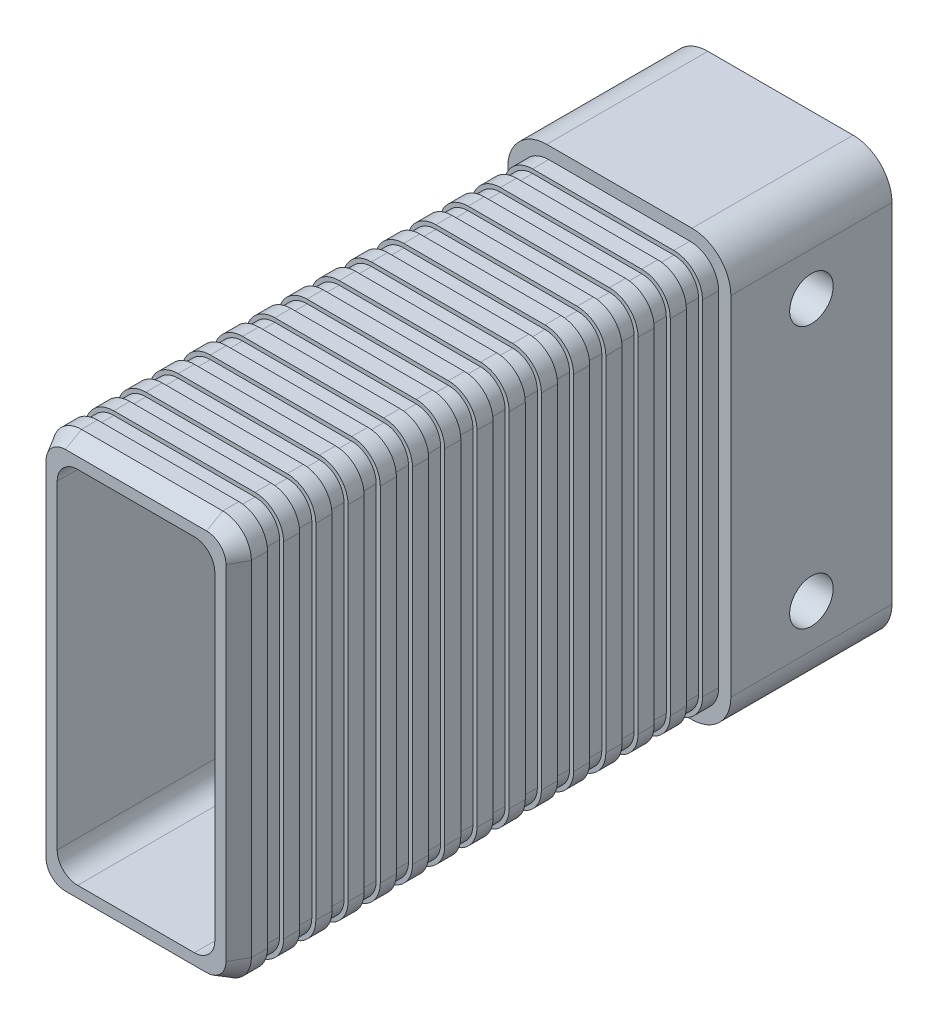
from build123d import *
from OCP.BRepFilletAPI import BRepFilletAPI_MakeChamfer

# Parameters (mm, degrees)
SKETCH1_W             = 24.646
SKETCH1_H             = 49.792
BOSS_EXTRUDE1_DEPTH   = 60
SKETCH2_W             = 27.686
SKETCH2_H             = 52.832
BOSS_EXTRUDE2_DEPTH   = 20
FILLET1_R             = 3.556
FILLET2_R             = 4.826
F_5_0MM_DOWEL_HOLE2_D = 5.4
CUT_EXTRUDE1_DEPTH    = 86.378180497
CUT_EXTRUDE2_START    = -4
CUT_EXTRUDE2_DEPTH    = 2
LPATTERN1_COUNT       = 14
LPATTERN1_PITCH       = 4
CHAMFER1_SIZE         = 2
CHAMFER1_SIZE2        = 1.154700538


with BuildPart() as part:
    # Sketch1 → Boss-Extrude1 (new body)
    with BuildSketch(Plane.XY):
        Rectangle(SKETCH1_W, SKETCH1_H)
    extrude(amount=BOSS_EXTRUDE1_DEPTH)

    # Sketch2 → Boss-Extrude2 (add)
    with BuildSketch(Plane.XY):
        Rectangle(SKETCH2_W, SKETCH2_H)
    extrude(amount=-BOSS_EXTRUDE2_DEPTH)

    # Fillet1
    fillet1_edges = [part.edges().sort_by_distance(p)[0] for p in [
        (-12.323, 24.896, 30),
        (12.323, 24.896, 30),
        (12.323, -24.896, 30),
        (-12.323, -24.896, 30),
    ]]
    fillet(fillet1_edges, radius=FILLET1_R)

    # Fillet2
    fillet2_edges = [part.edges().sort_by_distance(p)[0] for p in [
        (-13.843, -26.416, -10),
        (-13.843, 26.416, -10),
        (13.843, 26.416, -10),
        (13.843, -26.416, -10),
    ]]
    fillet(fillet2_edges, radius=FILLET2_R)

    # Ø5.0mm Dowel Hole2 (through all)
    with Locations(Plane(origin=(13.843, 0, 0), x_dir=(0, 0, -1), z_dir=(1, 0, 0))):
        with Locations((10, 16.256), (10, -16.256)):
            Hole(F_5_0MM_DOWEL_HOLE2_D / 2)

    # Sketch9 → Cut-Extrude1 (cut, through all)
    with BuildSketch(Plane.XY.offset(60)):
        with BuildLine():
            Line((7.243, -22.356), (-7.243, -22.356))
            ThreePointArc((-7.243, -22.356), (-9.039051224, -21.612051224), (-9.783, -19.816))
            Line((-9.783, -19.816), (-9.783, 19.816))
            ThreePointArc((-9.783, 19.816), (-9.039051224, 21.612051224), (-7.243, 22.356))
            Line((-7.243, 22.356), (7.243, 22.356))
            ThreePointArc((7.243, 22.356), (9.039051224, 21.612051224), (9.783, 19.816))
            Line((9.783, 19.816), (9.783, -19.816))
            ThreePointArc((9.783, -19.816), (9.039051224, -21.612051224), (7.243, -22.356))
        make_face()
    extrude(amount=-CUT_EXTRUDE1_DEPTH, mode=Mode.SUBTRACT)

    # Sketch10 → Cut-Extrude2 (cut)
    with BuildSketch(Plane.XY.offset(60).offset(CUT_EXTRUDE2_START)):
        with BuildLine():
            Line((-12.323, 21.34), (-12.323, -21.34))
            ThreePointArc((-12.323, -21.34), (-11.281471714, -23.854471714), (-8.767, -24.896))
            Line((-8.767, -24.896), (8.767, -24.896))
            ThreePointArc((8.767, -24.896), (11.281471714, -23.854471714), (12.323, -21.34))
            Line((12.323, -21.34), (12.323, 21.34))
            ThreePointArc((12.323, 21.34), (11.281471714, 23.854471714), (8.767, 24.896))
            Line((8.767, 24.896), (-8.767, 24.896))
            ThreePointArc((-8.767, 24.896), (-11.281471714, 23.854471714), (-12.323, 21.34))
        make_face()
        with BuildLine():
            Line((-11.823, 21.34), (-11.823, -21.34))
            ThreePointArc((-11.823, -21.34), (-10.927918323, -23.500918323), (-8.767, -24.396))
            Line((-8.767, -24.396), (8.767, -24.396))
            ThreePointArc((8.767, -24.396), (10.927918323, -23.500918323), (11.823, -21.34))
            Line((11.823, -21.34), (11.823, 21.34))
            ThreePointArc((11.823, 21.34), (10.927918323, 23.500918323), (8.767, 24.396))
            Line((8.767, 24.396), (-8.767, 24.396))
            ThreePointArc((-8.767, 24.396), (-10.927918323, 23.500918323), (-11.823, 21.34))
        make_face(mode=Mode.SUBTRACT)
    cut_extrude2 = extrude(amount=-CUT_EXTRUDE2_DEPTH, mode=Mode.SUBTRACT)

    # LPattern1: Cut-Extrude2 ×14
    with Locations(*[(0, 0, -i * LPATTERN1_PITCH) for i in range(1, LPATTERN1_COUNT)]):
        add(cut_extrude2, mode=Mode.SUBTRACT)

    # Chamfer1: one chamfer whose edges measure the first distance from different faces: ONE call of the kernel's chamfer builder (chamfer() names one face for all edges)
    chamfer1_edges_1 = [part.edges().sort_by_distance(p)[0] for p in [
        (0, -24.896, 60),
    ]]
    chamfer1_side_1 = [part.faces().sort_by_distance(p)[0] for p in [
        (0, -24.896, 58),
    ]]
    chamfer1_edges_2 = [part.edges().sort_by_distance(p)[0] for p in [
        (-12.323, 0, 60),
    ]]
    chamfer1_side_2 = [part.faces().sort_by_distance(p)[0] for p in [
        (-12.323, 0, 58),
    ]]
    chamfer1_edges_3 = [part.edges().sort_by_distance(p)[0] for p in [
        (12.323, 0, 60),
    ]]
    chamfer1_side_3 = [part.faces().sort_by_distance(p)[0] for p in [
        (12.323, 0, 58),
    ]]
    chamfer1_edges_4 = [part.edges().sort_by_distance(p)[0] for p in [
        (0, 24.896, 60),
    ]]
    chamfer1_side_4 = [part.faces().sort_by_distance(p)[0] for p in [
        (0, 24.896, 58),
    ]]
    chamfer1_edges_5 = [part.edges().sort_by_distance(p)[0] for p in [
        (-11.281471714, 23.854471714, 60),
    ]]
    chamfer1_side_5 = [part.faces().sort_by_distance(p)[0] for p in [
        (-11.281471714, 23.854471714, 58),
    ]]
    chamfer1_edges_6 = [part.edges().sort_by_distance(p)[0] for p in [
        (11.281471714, 23.854471714, 60),
    ]]
    chamfer1_side_6 = [part.faces().sort_by_distance(p)[0] for p in [
        (11.281471714, 23.854471714, 58),
    ]]
    chamfer1_edges_7 = [part.edges().sort_by_distance(p)[0] for p in [
        (11.281471714, -23.854471714, 60),
    ]]
    chamfer1_side_7 = [part.faces().sort_by_distance(p)[0] for p in [
        (11.281471714, -23.854471714, 58),
    ]]
    chamfer1_edges_8 = [part.edges().sort_by_distance(p)[0] for p in [
        (-11.281471714, -23.854471714, 60),
    ]]
    chamfer1_side_8 = [part.faces().sort_by_distance(p)[0] for p in [
        (-11.281471714, -23.854471714, 58),
    ]]
    chamfer1 = BRepFilletAPI_MakeChamfer(part.part.solid().wrapped)
    for e in chamfer1_edges_1:
        chamfer1.Add(CHAMFER1_SIZE, CHAMFER1_SIZE2, e.wrapped, chamfer1_side_1[0].wrapped)  # the first distance lies on this face
    for e in chamfer1_edges_2:
        chamfer1.Add(CHAMFER1_SIZE, CHAMFER1_SIZE2, e.wrapped, chamfer1_side_2[0].wrapped)  # the first distance lies on this face
    for e in chamfer1_edges_3:
        chamfer1.Add(CHAMFER1_SIZE, CHAMFER1_SIZE2, e.wrapped, chamfer1_side_3[0].wrapped)  # the first distance lies on this face
    for e in chamfer1_edges_4:
        chamfer1.Add(CHAMFER1_SIZE, CHAMFER1_SIZE2, e.wrapped, chamfer1_side_4[0].wrapped)  # the first distance lies on this face
    for e in chamfer1_edges_5:
        chamfer1.Add(CHAMFER1_SIZE, CHAMFER1_SIZE2, e.wrapped, chamfer1_side_5[0].wrapped)  # the first distance lies on this face
    for e in chamfer1_edges_6:
        chamfer1.Add(CHAMFER1_SIZE, CHAMFER1_SIZE2, e.wrapped, chamfer1_side_6[0].wrapped)  # the first distance lies on this face
    for e in chamfer1_edges_7:
        chamfer1.Add(CHAMFER1_SIZE, CHAMFER1_SIZE2, e.wrapped, chamfer1_side_7[0].wrapped)  # the first distance lies on this face
    for e in chamfer1_edges_8:
        chamfer1.Add(CHAMFER1_SIZE, CHAMFER1_SIZE2, e.wrapped, chamfer1_side_8[0].wrapped)  # the first distance lies on this face
    add(Compound.cast(chamfer1.Shape()), mode=Mode.REPLACE)


solid = part.part
